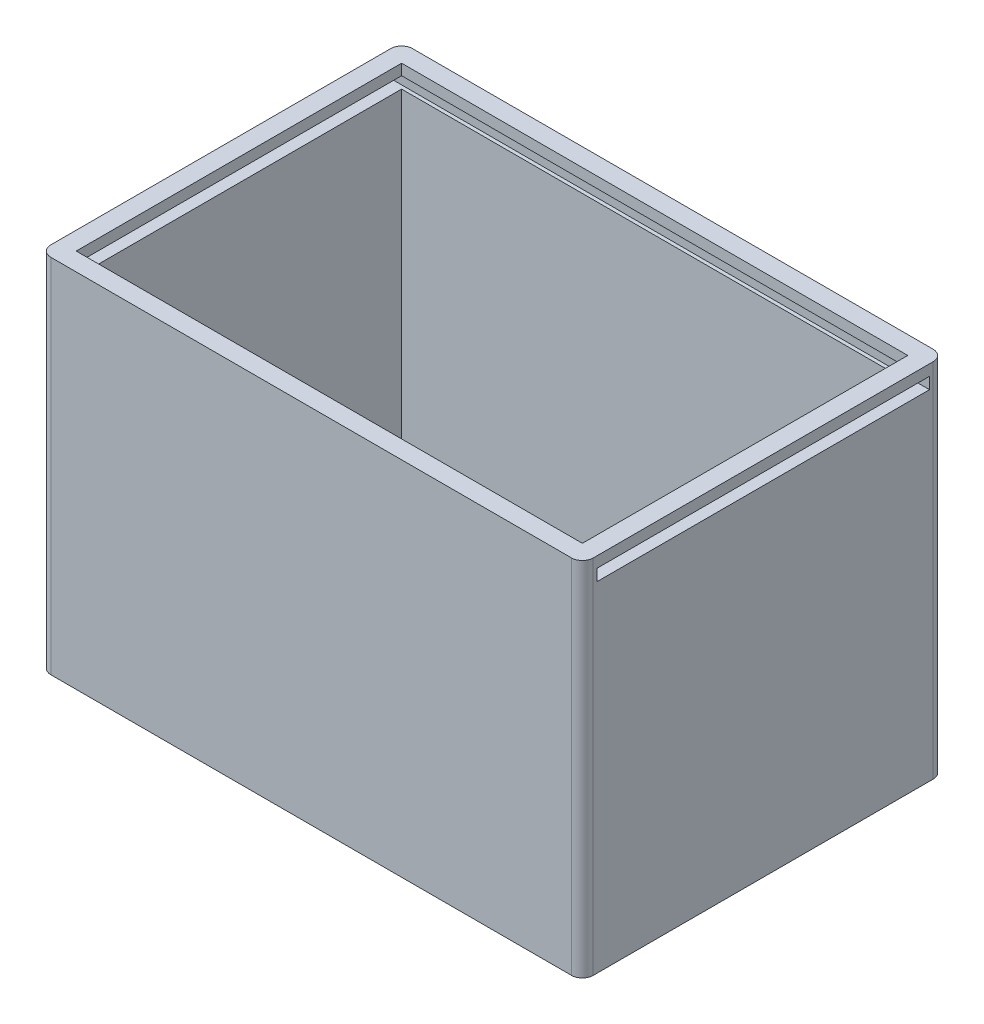
from build123d import *

# Parameters (mm, degrees)
BOSS_EXTRUDE1_DEPTH = 100
SKETCH3_W           = 140
SKETCH3_H           = 90
CUT_EXTRUDE1_DEPTH  = 105
SKETCH4_W           = 92
SKETCH4_H           = 3.2
CUT_EXTRUDE2_DEPTH  = 170
CUT_EXTRUDE3_DEPTH  = 12


with BuildPart() as part:
    # Sketch2 → Boss-Extrude1 (new body)
    with BuildSketch(Plane(origin=(0, 0, 0), x_dir=(1, 0, 0), z_dir=(0, 1, 0))):
        with BuildLine():
            Line((-72, 50), (72, 50))
            ThreePointArc((72, 50), (74.121320344, 49.121320344), (75, 47))
            Line((75, 47), (75, -47))
            ThreePointArc((75, -47), (74.121320344, -49.121320344), (72, -50))
            Line((72, -50), (-72, -50))
            ThreePointArc((-72, -50), (-74.121320344, -49.121320344), (-75, -47))
            Line((-75, -47), (-75, 47))
            ThreePointArc((-75, 47), (-74.121320344, 49.121320344), (-72, 50))
        make_face()
    extrude(amount=BOSS_EXTRUDE1_DEPTH)

    # Sketch3 → Cut-Extrude1 (cut)
    with BuildSketch(Plane(origin=(0, 110, 0), x_dir=(1, 0, 0), z_dir=(0, 1, 0))):
        Rectangle(SKETCH3_W, SKETCH3_H)
    extrude(amount=-CUT_EXTRUDE1_DEPTH, mode=Mode.SUBTRACT)

    # Sketch4 → Cut-Extrude2 (cut)
    with BuildSketch(Plane(origin=(85, 0, 0), x_dir=(0, 0, -1), z_dir=(1, 0, 0))):
        with Locations((0, 95.4)):
            Rectangle(SKETCH4_W, SKETCH4_H)
    extrude(amount=-CUT_EXTRUDE2_DEPTH, mode=Mode.SUBTRACT)

    # Sketch5 → Cut-Extrude3 (cut)
    with BuildSketch(Plane(origin=(0, 0, -60), x_dir=(-1, 0, 0), z_dir=(0, 0, -1))):
        with BuildLine():
            Line((-18.834688346, 54.851824829), (-16.979636931, 54.851824829))
            add(Edge.make_bspline(
                [(-16.979636931, 54.851824829), (-16.858430278, 54.851282282), (-16.624597238, 54.850235596), (-16.287390756, 54.83754313), (-15.976301265, 54.814797459), (-15.691400239, 54.786687406), (-15.432804822, 54.747278206), (-15.200191173, 54.702098643), (-14.993511021, 54.647056787), (-14.81043374, 54.581722866), (-14.646127793, 54.504696726), (-14.490641374, 54.422658389), (-14.347488493, 54.324748527), (-14.209443792, 54.221519449), (-14.084399523, 54.103109721), (-13.964554677, 53.977399683), (-13.854985011, 53.839403778), (-13.755182818, 53.690792408), (-13.664646851, 53.534311277), (-13.585548574, 53.369680642), (-13.521388481, 53.196639994), (-13.467566141, 53.016308708), (-13.424335513, 52.828694643), (-13.395559831, 52.632643957), (-13.37601394, 52.429525549), (-13.374289285, 52.291283033), (-13.373416979, 52.221361922)],
                knots=[0, 0, 0, 0, 1.698747864, 3.27724071, 4.728299578, 6.070144658, 7.288476769, 8.393259625, 9.389771311, 10.283485332, 11.113357557, 11.931608583, 12.74405601, 13.541433047, 14.344816069, 15.154114104, 15.974336324, 16.810834471, 17.661136416, 18.50621059, 19.367396281, 20.244825668, 21.142564693, 22.063065223, 23.020325768, 24, 24, 24, 24], degree=3))
            add(Edge.make_bspline(
                [(-13.373416979, 52.221361922), (-13.374679096, 52.144009862), (-13.377159313, 51.992003558), (-13.401473427, 51.769180966), (-13.443009615, 51.556739799), (-13.49729524, 51.352888502), (-13.572992685, 51.160980881), (-13.65947346, 50.976437961), (-13.765872245, 50.804433759), (-13.887449865, 50.64281671), (-14.020226497, 50.490272791), (-14.167354252, 50.351206419), (-14.326028812, 50.224669583), (-14.495331665, 50.109336168), (-14.675898427, 50.005438826), (-14.867598809, 49.91200467), (-15.07174185, 49.832022013), (-15.213900922, 49.790191732), (-15.285974988, 49.76898395)],
                knots=[0, 0, 0, 0, 1.102006807, 2.165578795, 3.188629044, 4.184801286, 5.166646146, 6.124351954, 7.085497154, 8.042432466, 9.003981491, 9.963833307, 10.922997304, 11.89326795, 12.880200226, 13.889073926, 14.929769137, 16, 16, 16, 16], degree=3))
            add(Edge.make_bspline(
                [(-15.285974988, 49.76898395), (-15.333447114, 49.757172808), (-15.436287026, 49.731586072), (-15.606458835, 49.705609112), (-15.802563976, 49.681724895), (-16.025236588, 49.661199302), (-16.274605045, 49.647246681), (-16.550427894, 49.636350305), (-16.852830134, 49.628427514), (-17.063108694, 49.628146379), (-17.172562278, 49.628000043)],
                knots=[0, 0, 0, 0, 0.618981996, 1.340914327, 2.176866532, 3.120127938, 4.170906482, 5.338178032, 6.614476169, 8, 8, 8, 8], degree=3))
            Line((-17.172562278, 49.628000043), (-17.172562278, 45.591408162))
            Line((-17.172562278, 45.591408162), (-18.834688346, 45.591408162))
            Line((-18.834688346, 45.591408162), (-18.834688346, 54.851824829))
        make_face()
        with BuildLine():
            Line((-17.172562278, 51.290126111), (-16.584510979, 51.290126111))
            add(Edge.make_bspline(
                [(-16.584510979, 51.290126111), (-16.477505761, 51.290804607), (-16.280614571, 51.29205305), (-16.011730733, 51.310106261), (-15.795650509, 51.337677161), (-15.62494312, 51.377220207), (-15.490153467, 51.437232017), (-15.37390583, 51.506654379), (-15.274197265, 51.59443705), (-15.187864322, 51.694743772), (-15.118843736, 51.810001223), (-15.070981555, 51.93833266), (-15.039891223, 52.0770417), (-15.037019742, 52.173574011), (-15.035543047, 52.223216973)],
                knots=[0, 0, 0, 0, 1.8619151, 3.425951444, 4.686033666, 5.651700536, 6.461346321, 7.243864085, 7.999046032, 8.762387399, 9.539336099, 10.322741239, 11.137448474, 12, 12, 12, 12], degree=3))
            add(Edge.make_bspline(
                [(-15.035543047, 52.223216973), (-15.037004553, 52.266589382), (-15.039840225, 52.350742284), (-15.060671844, 52.472195795), (-15.093871454, 52.585415522), (-15.141976411, 52.689219034), (-15.204164731, 52.783429954), (-15.279984877, 52.868011168), (-15.368463929, 52.944774054), (-15.43677493, 52.985405822), (-15.47148013, 53.006048671)],
                knots=[0, 0, 0, 0, 1.102301479, 2.1387299, 3.123554645, 4.094223062, 5.036071848, 5.982632524, 6.975082478, 8, 8, 8, 8], degree=3))
            add(Edge.make_bspline(
                [(-15.47148013, 53.006048671), (-15.500877437, 53.020915732), (-15.563117562, 53.052392348), (-15.669118529, 53.088986215), (-15.791442026, 53.119857173), (-15.930913874, 53.145479771), (-16.086977681, 53.165365567), (-16.259605602, 53.180573227), (-16.449051675, 53.186688819), (-16.580800083, 53.188667774), (-16.649437779, 53.189698761)],
                knots=[0, 0, 0, 0, 0.656809284, 1.390599849, 2.23162475, 3.173112763, 4.218524733, 5.370385145, 6.63003504, 8, 8, 8, 8], degree=3))
            Line((-16.649437779, 53.189698761), (-17.172562278, 53.189698761))
            Line((-17.172562278, 53.189698761), (-17.172562278, 51.290126111))
        make_face(mode=Mode.SUBTRACT)
        Polygon((-11.71129091, 54.851824829), (-10.049164842, 54.851824829), (-10.049164842, 51.290126111), (-6.843635996, 51.290126111), (-6.843635996, 54.851824829), (-5.181509927, 54.851824829), (-5.181509927, 45.591408162), (-6.843635996, 45.591408162), (-6.843635996, 49.628000043), (-10.049164842, 49.628000043), (-10.049164842, 45.591408162), (-11.71129091, 45.591408162), align=None)
        Polygon((-2.311745387, 54.851824829), (-0.586547571, 54.851824829), (1.526355991, 48.3925358), (3.654099965, 54.851824829), (5.362602319, 54.851824829), (6.928265714, 45.591408162), (5.24573408, 45.591408162), (4.256991675, 51.440385276), (2.331448306, 45.591408162), (0.710133369, 45.591408162), (-1.204279692, 51.440385276), (-2.191167045, 45.591408162), (-3.875553731, 45.591408162), align=None)
        with BuildLine():
            Line((11.046479856, 55.08927141), (12.517535629, 54.343540741))
            Line((12.517535629, 54.343540741), (10.903640897, 51.17140282))
            add(Edge.make_bspline(
                [(10.903640897, 51.17140282), (10.998988284, 51.168934229), (11.186790598, 51.164071932), (11.463103595, 51.124774038), (11.727263965, 51.056837401), (11.981935223, 50.966787574), (12.224004256, 50.845849761), (12.457369719, 50.701987923), (12.675994331, 50.526532938), (12.884890966, 50.332138124), (13.074839603, 50.116776607), (13.239843576, 49.885363816), (13.383641625, 49.643530053), (13.495424441, 49.385864908), (13.585592183, 49.116639475), (13.650652177, 48.834777544), (13.687770724, 48.539462906), (13.692888135, 48.338842295), (13.695493278, 48.236711481)],
                knots=[0, 0, 0, 0, 1.013260694, 1.995783107, 2.958651975, 3.908806537, 4.861209129, 5.829647963, 6.817170299, 7.835534541, 8.860094905, 9.863329007, 10.853101798, 11.844815043, 12.84250023, 13.867713965, 14.914507806, 16, 16, 16, 16], degree=3))
            add(Edge.make_bspline(
                [(13.695493278, 48.236711481), (13.693052043, 48.138263572), (13.68822677, 47.943674272), (13.648339497, 47.65787208), (13.583879568, 47.38366159), (13.491753386, 47.121590435), (13.374653557, 46.870377604), (13.231448399, 46.630170511), (13.060950302, 46.402764144), (12.867564466, 46.189366833), (12.656160386, 45.994853605), (12.433328971, 45.821958929), (12.197181975, 45.679141366), (11.952182854, 45.558528586), (11.693821024, 45.468525324), (11.425962881, 45.400588452), (11.146577181, 45.361385928), (10.956937326, 45.356456167), (10.860974715, 45.353961581)],
                knots=[0, 0, 0, 0, 1.049934834, 2.075270938, 3.072134561, 4.05064612, 5.033440221, 6.024524368, 7.028587226, 8.060776465, 9.092543989, 10.090062252, 11.064205434, 12.031961459, 12.998029633, 13.977230324, 14.976426867, 16, 16, 16, 16], degree=3))
            add(Edge.make_bspline(
                [(10.860974715, 45.353961581), (10.760626985, 45.356008755), (10.563306752, 45.360034246), (10.274577867, 45.405109129), (9.997662017, 45.472963083), (9.734115514, 45.569847001), (9.482299441, 45.693210292), (9.245178476, 45.845859958), (9.020755206, 46.026112681), (8.811422311, 46.229913059), (8.622828972, 46.453148489), (8.454619476, 46.684924986), (8.312314025, 46.925606259), (8.19712108, 47.174934973), (8.107244873, 47.432116632), (8.044709363, 47.697639345), (8.003961708, 47.970798813), (7.999184974, 48.156180286), (7.996775329, 48.249696841)],
                knots=[0, 0, 0, 0, 1.063775006, 2.091769615, 3.092589432, 4.084662827, 5.064601646, 6.061867366, 7.070035304, 8.113879863, 9.156342271, 10.166834137, 11.149076039, 12.117706134, 13.076241869, 14.034148791, 15.008317125, 16, 16, 16, 16], degree=3))
            add(Edge.make_bspline(
                [(7.996775329, 48.249696841), (7.998048538, 48.322114473), (8.000602044, 48.467352842), (8.026263251, 48.684839409), (8.0652773, 48.902896857), (8.11049969, 49.086900636), (8.157065139, 49.242495088), (8.203933621, 49.374170469), (8.262016777, 49.520301349), (8.328414429, 49.681260888), (8.40521454, 49.856855451), (8.492015921, 50.046606415), (8.589034668, 50.251950716), (8.658222397, 50.392990454), (8.694274661, 50.466483283)],
                knots=[0, 0, 0, 0, 1.110454016, 2.227089276, 3.35462975, 4.507227546, 5.131400587, 5.845402449, 6.650387134, 7.543487832, 8.516250726, 9.590168902, 10.744287919, 12, 12, 12, 12], degree=3))
            Line((8.694274661, 50.466483283), (11.046479856, 55.08927141))
        make_face()
        with BuildLine():
            add(Edge.make_bspline(
                [(10.823873686, 49.628000043), (10.744119819, 49.624341901), (10.588051969, 49.617183399), (10.366146827, 49.542216076), (10.163819684, 49.424611004), (9.988440014, 49.260823197), (9.841751058, 49.065090336), (9.733958866, 48.841830864), (9.669115871, 48.594024117), (9.6623791, 48.420761771), (9.658901397, 48.331319103)],
                knots=[0, 0, 0, 0, 0.981744412, 1.921144944, 2.858899012, 3.85339082, 4.86292663, 5.863643845, 6.897155691, 8, 8, 8, 8], degree=3))
            add(Edge.make_bspline(
                [(9.658901397, 48.331319103), (9.663019106, 48.241846651), (9.671028324, 48.067816751), (9.738309499, 47.817650441), (9.84846966, 47.589321006), (10.002962261, 47.390994259), (10.184334354, 47.226367705), (10.385454493, 47.104618497), (10.602967921, 47.029823963), (10.753427272, 47.020698037), (10.829438841, 47.01608765)],
                knots=[0, 0, 0, 0, 1.098279937, 2.136227893, 3.159405121, 4.194678092, 5.206500211, 6.154139736, 7.067477469, 8, 8, 8, 8], degree=3))
            add(Edge.make_bspline(
                [(10.829438841, 47.01608765), (10.909715649, 47.020780151), (11.067152411, 47.029982963), (11.294265267, 47.101630279), (11.501734224, 47.221339789), (11.685176913, 47.385439278), (11.842750697, 47.581502849), (11.951775839, 47.81117346), (12.022167453, 48.063145381), (12.029550255, 48.239923639), (12.033367209, 48.331319103)],
                knots=[0, 0, 0, 0, 0.96921794, 1.900804717, 2.848419905, 3.844199796, 4.861108892, 5.867439427, 6.897452859, 8, 8, 8, 8], degree=3))
            add(Edge.make_bspline(
                [(12.033367209, 48.331319103), (12.029019001, 48.420709546), (12.020598187, 48.593824576), (11.957347899, 48.842792241), (11.844418781, 49.065191189), (11.694410869, 49.261631151), (11.512995562, 49.425345925), (11.302570874, 49.543143546), (11.070528735, 49.617050581), (10.907290785, 49.624297008), (10.823873686, 49.628000043)],
                knots=[0, 0, 0, 0, 1.083229974, 2.097801324, 3.086792542, 4.086858909, 5.079819718, 6.026392613, 6.991456328, 8, 8, 8, 8], degree=3))
        make_face(mode=Mode.SUBTRACT)
        with BuildLine():
            Line((18.169877292, 55.08927141), (19.640933065, 54.343540741))
            Line((19.640933065, 54.343540741), (18.027038333, 51.17140282))
            add(Edge.make_bspline(
                [(18.027038333, 51.17140282), (18.12238572, 51.168934229), (18.310188033, 51.164071932), (18.586501031, 51.124774038), (18.850661401, 51.056837401), (19.105332659, 50.966787574), (19.347401692, 50.845849761), (19.580767155, 50.701987923), (19.799391767, 50.526532938), (20.008288402, 50.332138124), (20.198237039, 50.116776607), (20.363241012, 49.885363816), (20.507039061, 49.643530053), (20.618821877, 49.385864908), (20.708989619, 49.116639475), (20.774049613, 48.834777544), (20.81116816, 48.539462906), (20.816285571, 48.338842295), (20.818890714, 48.236711481)],
                knots=[0, 0, 0, 0, 1.013260694, 1.995783107, 2.958651975, 3.908806537, 4.861209129, 5.829647963, 6.817170299, 7.835534541, 8.860094905, 9.863329007, 10.853101798, 11.844815043, 12.84250023, 13.867713965, 14.914507806, 16, 16, 16, 16], degree=3))
            add(Edge.make_bspline(
                [(20.818890714, 48.236711481), (20.816449479, 48.138263572), (20.811624206, 47.943674272), (20.771736933, 47.65787208), (20.707277004, 47.38366159), (20.615150821, 47.121590435), (20.498050993, 46.870377604), (20.354845835, 46.630170511), (20.184347738, 46.402764144), (19.990961902, 46.189366833), (19.779557822, 45.994853605), (19.556726406, 45.821958929), (19.320579411, 45.679141366), (19.07558029, 45.558528586), (18.81721846, 45.468525324), (18.549360317, 45.400588452), (18.269974617, 45.361385928), (18.080334762, 45.356456167), (17.984372151, 45.353961581)],
                knots=[0, 0, 0, 0, 1.049934834, 2.075270938, 3.072134561, 4.05064612, 5.033440221, 6.024524368, 7.028587226, 8.060776465, 9.092543989, 10.090062252, 11.064205434, 12.031961459, 12.998029633, 13.977230324, 14.976426867, 16, 16, 16, 16], degree=3))
            add(Edge.make_bspline(
                [(17.984372151, 45.353961581), (17.884024421, 45.356008755), (17.686704188, 45.360034246), (17.397975303, 45.405109129), (17.121059453, 45.472963083), (16.85751295, 45.569847001), (16.605696876, 45.693210292), (16.368575912, 45.845859958), (16.144152642, 46.026112681), (15.934819747, 46.229913059), (15.746226408, 46.453148489), (15.578016912, 46.684924986), (15.435711461, 46.925606259), (15.320518516, 47.174934973), (15.230642308, 47.432116632), (15.168106799, 47.697639345), (15.127359143, 47.970798813), (15.12258241, 48.156180286), (15.120172765, 48.249696841)],
                knots=[0, 0, 0, 0, 1.063775006, 2.091769615, 3.092589432, 4.084662827, 5.064601646, 6.061867366, 7.070035304, 8.113879863, 9.156342271, 10.166834137, 11.149076039, 12.117706134, 13.076241869, 14.034148791, 15.008317125, 16, 16, 16, 16], degree=3))
            add(Edge.make_bspline(
                [(15.120172765, 48.249696841), (15.121445974, 48.322114473), (15.12399948, 48.467352842), (15.149660687, 48.684839409), (15.188674736, 48.902896857), (15.233897126, 49.086900636), (15.280462575, 49.242495088), (15.327331057, 49.374170469), (15.385414213, 49.520301349), (15.451811865, 49.681260888), (15.528611976, 49.856855451), (15.615413357, 50.046606415), (15.712432104, 50.251950716), (15.781619833, 50.392990454), (15.817672097, 50.466483283)],
                knots=[0, 0, 0, 0, 1.110454016, 2.227089276, 3.35462975, 4.507227546, 5.131400587, 5.845402449, 6.650387134, 7.543487832, 8.516250726, 9.590168902, 10.744287919, 12, 12, 12, 12], degree=3))
            Line((15.817672097, 50.466483283), (18.169877292, 55.08927141))
        make_face()
        with BuildLine():
            add(Edge.make_bspline(
                [(17.947271122, 49.628000043), (17.867517255, 49.624341901), (17.711449405, 49.617183399), (17.489544263, 49.542216076), (17.28721712, 49.424611004), (17.11183745, 49.260823197), (16.965148494, 49.065090336), (16.857356302, 48.841830864), (16.792513307, 48.594024117), (16.785776535, 48.420761771), (16.782298833, 48.331319103)],
                knots=[0, 0, 0, 0, 0.981744412, 1.921144944, 2.858899012, 3.85339082, 4.86292663, 5.863643845, 6.897155691, 8, 8, 8, 8], degree=3))
            add(Edge.make_bspline(
                [(16.782298833, 48.331319103), (16.786416542, 48.241846651), (16.79442576, 48.067816751), (16.861706935, 47.817650441), (16.971867096, 47.589321006), (17.126359697, 47.390994259), (17.30773179, 47.226367705), (17.508851929, 47.104618497), (17.726365357, 47.029823963), (17.876824708, 47.020698037), (17.952836277, 47.01608765)],
                knots=[0, 0, 0, 0, 1.098279937, 2.136227893, 3.159405121, 4.194678092, 5.206500211, 6.154139736, 7.067477469, 8, 8, 8, 8], degree=3))
            add(Edge.make_bspline(
                [(17.952836277, 47.01608765), (18.033113084, 47.020780151), (18.190549847, 47.029982963), (18.417662703, 47.101630279), (18.62513166, 47.221339789), (18.808574349, 47.385439278), (18.966148133, 47.581502849), (19.075173275, 47.81117346), (19.145564889, 48.063145381), (19.152947691, 48.239923639), (19.156764645, 48.331319103)],
                knots=[0, 0, 0, 0, 0.96921794, 1.900804717, 2.848419905, 3.844199796, 4.861108892, 5.867439427, 6.897452859, 8, 8, 8, 8], degree=3))
            add(Edge.make_bspline(
                [(19.156764645, 48.331319103), (19.152416437, 48.420709546), (19.143995623, 48.593824576), (19.080745335, 48.842792241), (18.967816217, 49.065191189), (18.817808305, 49.261631151), (18.636392998, 49.425345925), (18.42596831, 49.543143546), (18.193926171, 49.617050581), (18.030688221, 49.624297008), (17.947271122, 49.628000043)],
                knots=[0, 0, 0, 0, 1.083229974, 2.097801324, 3.086792542, 4.086858909, 5.079819718, 6.026392613, 6.991456328, 8, 8, 8, 8], degree=3))
        make_face(mode=Mode.SUBTRACT)
    extrude(amount=-CUT_EXTRUDE3_DEPTH, mode=Mode.SUBTRACT)


solid = part.part
